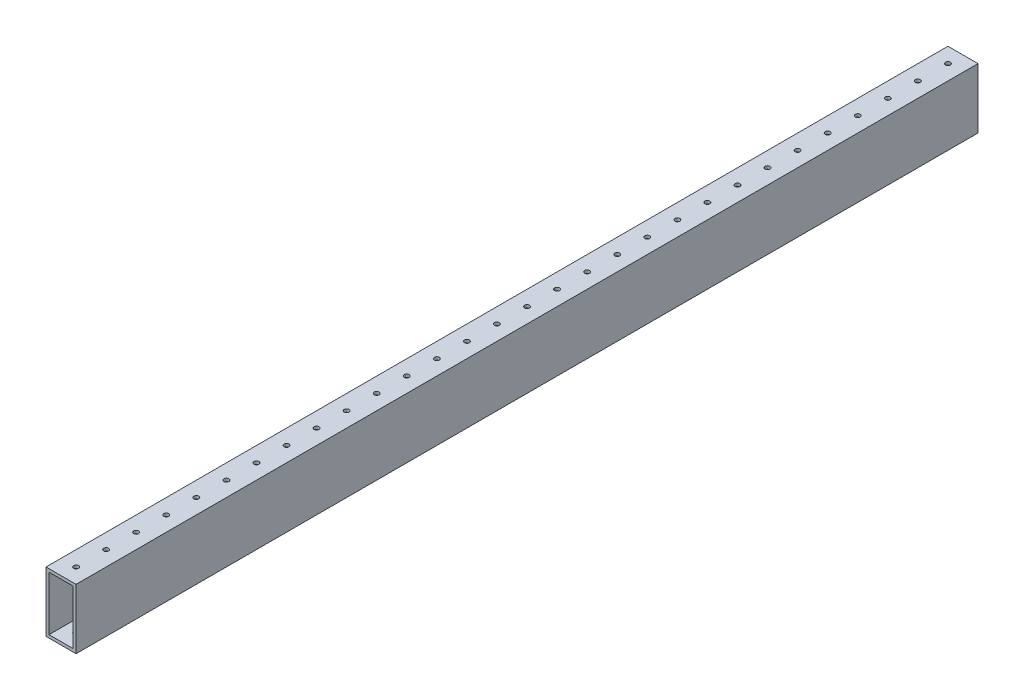
from build123d import *

# Parameters (mm, degrees)
SKETCH1_W           = 25.4
SKETCH1_H           = 50.8
SKETCH1_W_2         = 20.32
SKETCH1_H_2         = 45.72
EXTRUDE_THIN1_DEPTH = 381
SKETCH2_R           = 2.0701
CUT_EXTRUDE1_DEPTH  = 51.8
LPATTERN1_COUNT     = 31
LPATTERN1_PITCH     = 25.4


with BuildPart() as part:
    # Sketch1 → Extrude-Thin1 (new body, symmetric)
    with BuildSketch(Plane.XY):
        Rectangle(SKETCH1_W, SKETCH1_H)
        Rectangle(SKETCH1_W_2, SKETCH1_H_2, mode=Mode.SUBTRACT)
    extrude(amount=EXTRUDE_THIN1_DEPTH, both=True)

    # Sketch2 → Cut-Extrude1 (cut, through all)
    with BuildSketch(Plane(origin=(0, 25.4, 0), x_dir=(1, 0, 0), z_dir=(0, 1, 0))):
        with Locations((0, -368.3)):
            Circle(SKETCH2_R)
    cut_extrude1 = extrude(amount=-CUT_EXTRUDE1_DEPTH, mode=Mode.SUBTRACT)

    # LPattern1: Cut-Extrude1 ×31
    with Locations(*[(0, 0, -i * LPATTERN1_PITCH) for i in range(1, LPATTERN1_COUNT)]):
        add(cut_extrude1, mode=Mode.SUBTRACT)


solid = part.part
